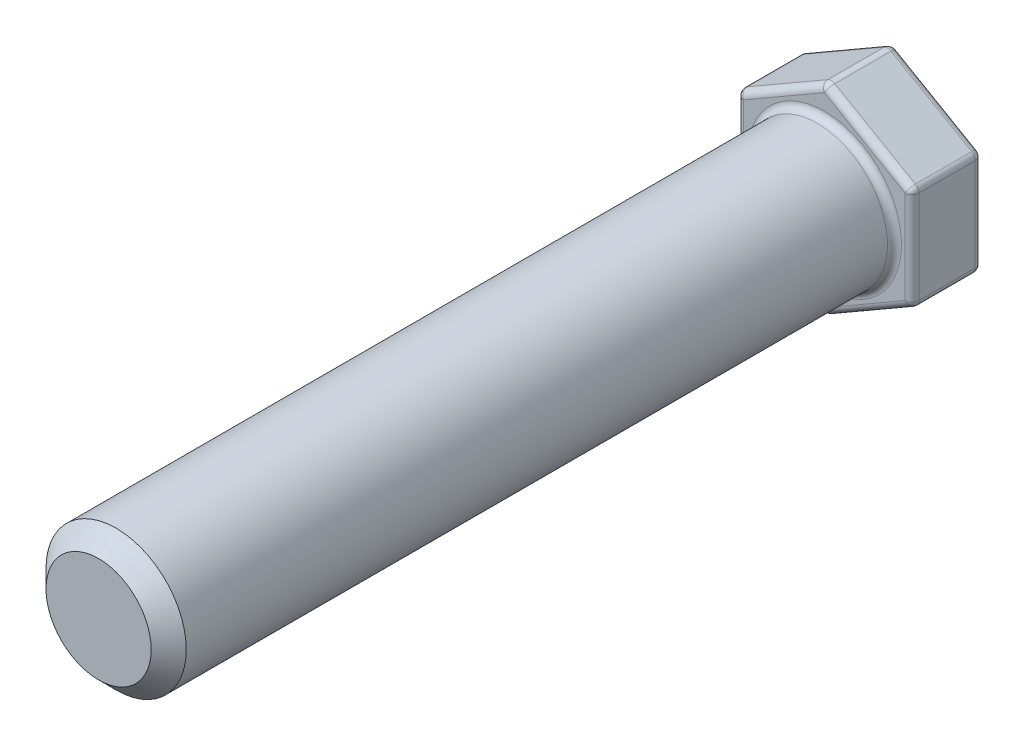
from build123d import *

# Parameters (mm, degrees)
SKETCH1_R           = 2
BOSS_EXTRUDE1_DEPTH = 20.7
BOSS_EXTRUDE2_DEPTH = 2
FILLET1_R           = 0.2
FILLET2_R           = 0.2
CHAMFER1_SIZE       = 0.5


with BuildPart() as part:
    # Sketch1 → Boss-Extrude1 (new body)
    with BuildSketch(Plane.XY):
        Circle(SKETCH1_R)
    extrude(amount=BOSS_EXTRUDE1_DEPTH)

    # Sketch2 → Boss-Extrude2 (add)
    with BuildSketch(Plane(origin=(0, 0, 0), x_dir=(-1, 0, 0), z_dir=(0, 0, -1))):
        Polygon((-2.5, 1.443375673), (-2.5, -1.443375673), (0, -2.886751346), (2.5, -1.443375673), (2.5, 1.443375673), (0, 2.886751346), align=None)
    extrude(amount=BOSS_EXTRUDE2_DEPTH)

    # Fillet1
    fillet1_edges = [part.edges().sort_by_distance(p)[0] for p in [
        (-2, 0, 0),
        (1.25, 2.165063509, 0),
        (2.5, 0, 0),
        (1.25, -2.165063509, 0),
        (-1.25, -2.165063509, 0),
        (-2.5, 0, 0),
        (-1.25, 2.165063509, 0),
        (1.25, 2.165063509, -2),
        (2.5, 0, -2),
        (1.25, -2.165063509, -2),
        (-1.25, -2.165063509, -2),
        (-2.5, 0, -2),
        (-1.25, 2.165063509, -2),
    ]]
    fillet(fillet1_edges, radius=FILLET1_R)

    # Fillet2
    fillet2_edges = [part.edges().sort_by_distance(p)[0] for p in [
        (0, 2.886751346, -1),
        (-2.5, 1.443375673, -1),
        (-2.5, -1.443375673, -1),
        (0, -2.886751346, -1),
        (2.5, -1.443375673, -1),
        (2.5, 1.443375673, -1),
        (0, -2.813180543, -1.94637683),
        (2.436285816, -1.406590271, -1.94637683),
        (-2.436285816, -1.406590271, -1.94637683),
        (2.436285816, 1.406590271, -1.94637683),
        (-2.436285816, 1.406590271, -1.94637683),
        (0, 2.813180543, -1.94637683),
        (-2.436285816, 1.406590271, -0.05362317),
        (-2.436285816, -1.406590271, -0.05362317),
        (0, 2.813180543, -0.05362317),
        (0, -2.813180543, -0.05362317),
        (2.436285816, 1.406590271, -0.05362317),
        (2.436285816, -1.406590271, -0.05362317),
    ]]
    fillet(fillet2_edges, radius=FILLET2_R)

    # Chamfer1
    chamfer1_edges = [part.edges().sort_by_distance(p)[0] for p in [
        (-2, 0, 20.7),
    ]]
    chamfer(chamfer1_edges, length=CHAMFER1_SIZE)


solid = part.part
